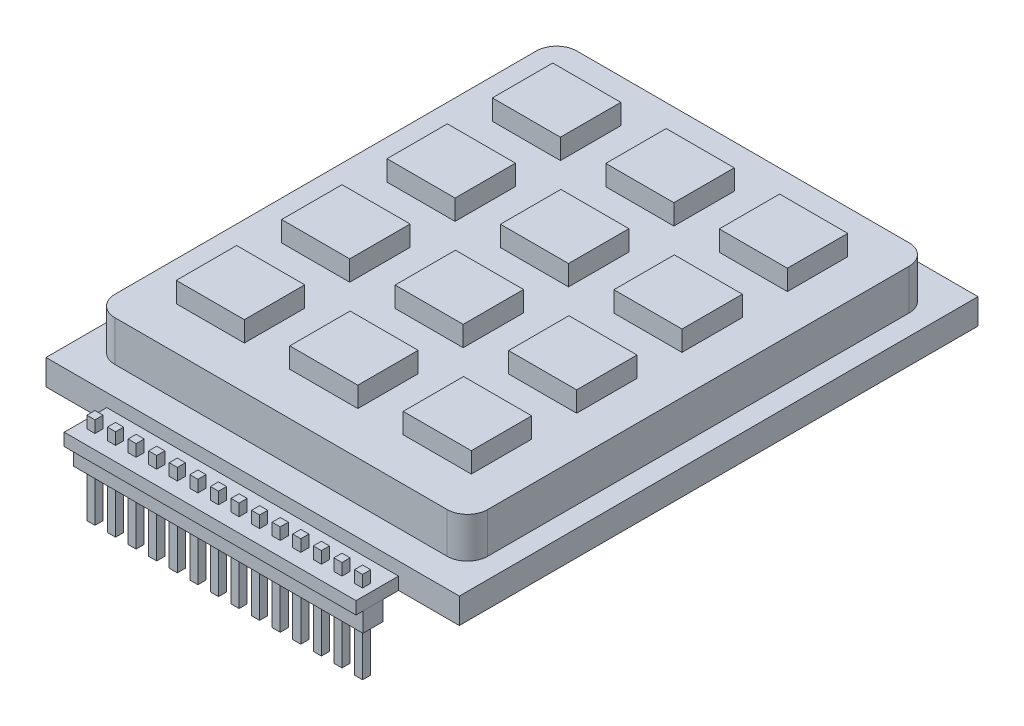
from build123d import *

# Parameters (mm, degrees)
ESQUISSE1_W             = 51
ESQUISSE1_H             = 64
BOSS_EXTRU_1_DEPTH      = 3.15
BOSS_EXTRU_2_DEPTH      = 5
ESQUISSE3_W             = 8.4
ESQUISSE3_H             = 7.45
BOSS_EXTRU_3_DEPTH      = 2.5
ESQUISSE4_W             = 36
ESQUISSE4_H             = 5.25
BOSS_EXTRU_4_DEPTH      = 1.54
ESQUISSE5_W             = 35.72
ESQUISSE5_H             = 2.5
BOSS_EXTRU_5_DEPTH      = 2.52
ESQUISSE6_W             = 1
ESQUISSE6_H             = 1
BOSS_EXTRU_6_DEPTH      = 5.75
BOSS_EXTRU_6_DEPTH_BACK = 5.52


with BuildPart() as part:
    # Esquisse1 → Boss.-Extru.1 (new body)
    with BuildSketch(Plane(origin=(0, 0, 0), x_dir=(1, 0, 0), z_dir=(0, 1, 0))):
        with Locations((25.5, 32)):
            Rectangle(ESQUISSE1_W, ESQUISSE1_H)
    extrude(amount=BOSS_EXTRU_1_DEPTH)

    # Esquisse2 → Boss.-Extru.2 (add)
    with BuildSketch(Plane(origin=(0, 3.15, 0), x_dir=(1, 0, 0), z_dir=(0, 1, 0))):
        with BuildLine():
            Line((2.5, 58), (2.5, 6))
            ThreePointArc((2.5, 6), (3.232233047, 4.232233047), (5, 3.5))
            Line((5, 3.5), (46, 3.5))
            ThreePointArc((46, 3.5), (47.767766953, 4.232233047), (48.5, 6))
            Line((48.5, 6), (48.5, 58))
            ThreePointArc((48.5, 58), (47.767766953, 59.767766953), (46, 60.5))
            Line((46, 60.5), (5, 60.5))
            ThreePointArc((5, 60.5), (3.232233047, 59.767766953), (2.5, 58))
        make_face()
    extrude(amount=BOSS_EXTRU_2_DEPTH)

    # Esquisse3 → Boss.-Extru.3 (add)
    with BuildSketch(Plane(origin=(0, 8.15, 0), x_dir=(1, 0, 0), z_dir=(0, 1, 0))):
        with Locations((11.5, 38.5)):
            Rectangle(ESQUISSE3_W, ESQUISSE3_H)
        with Locations((11.5, 51.5)):
            Rectangle(ESQUISSE3_W, ESQUISSE3_H)
        with Locations((25.5, 51.5)):
            Rectangle(ESQUISSE3_W, ESQUISSE3_H)
        with Locations((39.5, 51.5)):
            Rectangle(ESQUISSE3_W, ESQUISSE3_H)
        with Locations((25.5, 38.5)):
            Rectangle(ESQUISSE3_W, ESQUISSE3_H)
        with Locations((39.5, 38.5)):
            Rectangle(ESQUISSE3_W, ESQUISSE3_H)
        with Locations((11.5, 12.5)):
            Rectangle(ESQUISSE3_W, ESQUISSE3_H)
        with Locations((11.5, 25.5)):
            Rectangle(ESQUISSE3_W, ESQUISSE3_H)
        with Locations((25.5, 25.5)):
            Rectangle(ESQUISSE3_W, ESQUISSE3_H)
        with Locations((39.5, 25.5)):
            Rectangle(ESQUISSE3_W, ESQUISSE3_H)
        with Locations((25.5, 12.5)):
            Rectangle(ESQUISSE3_W, ESQUISSE3_H)
        with Locations((39.5, 12.5)):
            Rectangle(ESQUISSE3_W, ESQUISSE3_H)
    extrude(amount=BOSS_EXTRU_3_DEPTH)

    # Esquisse4 → Boss.-Extru.4 (add)
    with BuildSketch(Plane.XZ):
        with Locations((25.5, 2.625)):
            Rectangle(ESQUISSE4_W, ESQUISSE4_H)
    extrude(amount=-BOSS_EXTRU_4_DEPTH)

    # Esquisse5 → Boss.-Extru.5 (add)
    with BuildSketch(Plane.XZ):
        with Locations((25.5, 3)):
            Rectangle(ESQUISSE5_W, ESQUISSE5_H)
    extrude(amount=BOSS_EXTRU_5_DEPTH)

    # Esquisse6 → Boss.-Extru.6 (add, two sides)
    with BuildSketch(Plane.XZ.offset(2.52)) as boss_extru_6_sk:
        with Locations((9.041511345, 3)):
            Rectangle(ESQUISSE6_W, ESQUISSE6_H)
        with Locations((11.581511345, 3)):
            Rectangle(ESQUISSE6_W, ESQUISSE6_H)
        with Locations((14.121511345, 3)):
            Rectangle(ESQUISSE6_W, ESQUISSE6_H)
        with Locations((16.661511345, 3)):
            Rectangle(ESQUISSE6_W, ESQUISSE6_H)
        with Locations((19.201511345, 3)):
            Rectangle(ESQUISSE6_W, ESQUISSE6_H)
        with Locations((21.741511345, 3)):
            Rectangle(ESQUISSE6_W, ESQUISSE6_H)
        with Locations((24.281511345, 3)):
            Rectangle(ESQUISSE6_W, ESQUISSE6_H)
        with Locations((26.821511345, 3)):
            Rectangle(ESQUISSE6_W, ESQUISSE6_H)
        with Locations((29.361511345, 3)):
            Rectangle(ESQUISSE6_W, ESQUISSE6_H)
        with Locations((31.901511345, 3)):
            Rectangle(ESQUISSE6_W, ESQUISSE6_H)
        with Locations((34.441511345, 3)):
            Rectangle(ESQUISSE6_W, ESQUISSE6_H)
        with Locations((36.981511345, 3)):
            Rectangle(ESQUISSE6_W, ESQUISSE6_H)
        with Locations((39.521511345, 3)):
            Rectangle(ESQUISSE6_W, ESQUISSE6_H)
        with Locations((42.061511345, 3)):
            Rectangle(ESQUISSE6_W, ESQUISSE6_H)
    extrude(amount=BOSS_EXTRU_6_DEPTH)
    extrude(boss_extru_6_sk.sketch, amount=-BOSS_EXTRU_6_DEPTH_BACK)


solid = part.part
